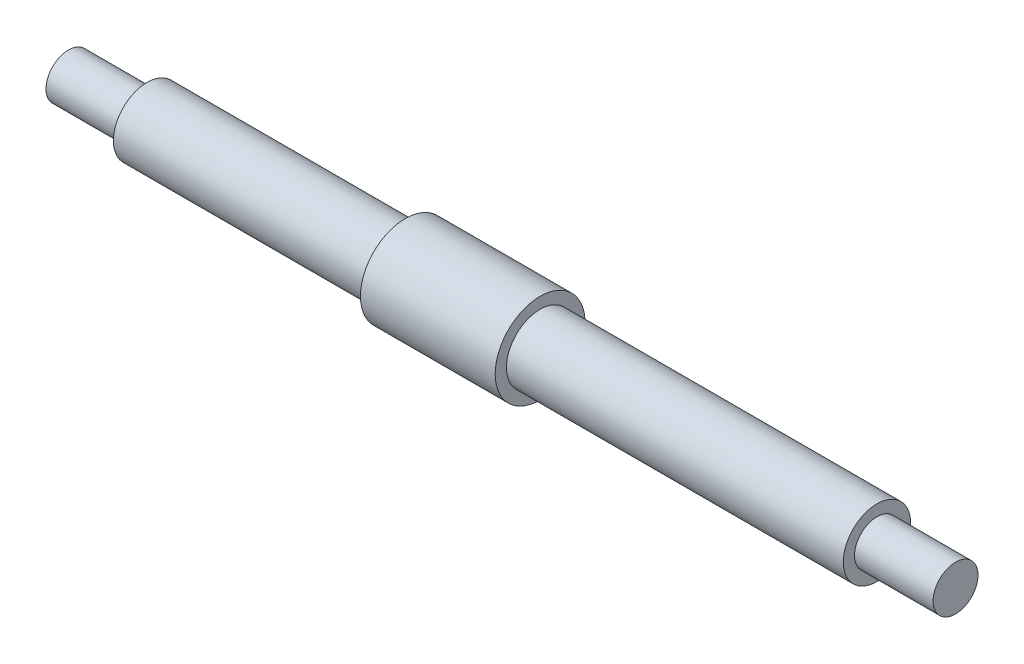
from build123d import *


with BuildPart() as part:
    # Esquisse1 → Révolution1 (revolve)
    with BuildSketch(Plane.XY, mode=Mode.PRIVATE) as r_volution1_sk:
        Polygon((42, 3), (72, 3), (72, 2), (79, 2), (79, 0), (0, 0), (0, 2), (7, 2), (7, 3), (30, 3), (30, 4), (42, 4), align=None)
    revolve(r_volution1_sk.sketch.rotate(Axis((0, 0, 0), (1, 0, 0)), 90), axis=Axis((0, 0, 0), (1, 0, 0)))  # turned: the seam where the file's is


solid = part.part
